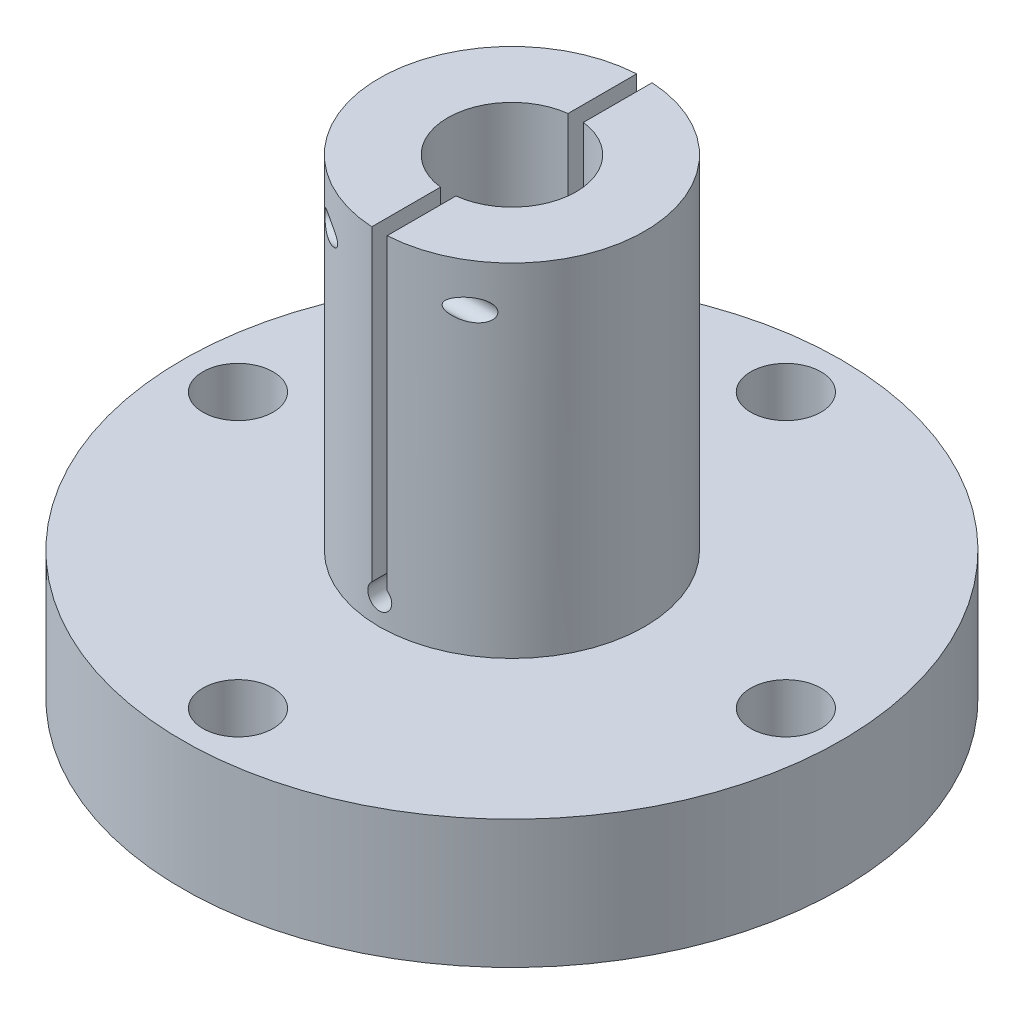
from build123d import *

# Parameters (mm, degrees)
CUT_EXTRUDE1_DEPTH      = 78.391860037
CUT_EXTRUDE1_DEPTH_BACK = 78.391860037
CUT_EXTRUDE2_START      = -2.5
SKETCH3_R               = 1.25
CUT_EXTRUDE2_DEPTH      = 76.343496909
SKETCH4_R               = 0.5
CUT_EXTRUDE3_DEPTH      = 80.13823356
SKETCH5_R               = 2.25
CUT_EXTRUDE4_DEPTH      = 78.391860108
SKETCH6_R               = 4.1
CUT_EXTRUDE5_DEPTH      = 9
CIRPATTERN1_COUNT       = 4


with BuildPart() as part:
    # Sketch1 → Revolve1 (revolve)
    with BuildSketch(Plane.XY):
        Polygon((7.5, 55), (7.5, 15), (9, 15), (9, 7), (25, 7), (25, 0), (38.5, 0), (38.5, 15), (15.5, 15), (15.5, 55), align=None)
    revolve(axis=Axis((0, 0, 0), (0, 1, 0)))

    # Sketch2 → Cut-Extrude1 (cut, two sides: drawn at the far end of the back side and taken through both)
    with BuildSketch(Plane.XY.offset(-CUT_EXTRUDE1_DEPTH_BACK)):
        with BuildLine():
            Line((-0.9, 55), (0.9, 55))
            Line((0.9, 55), (0.9, 19.072380529))
            ThreePointArc((0.9, 19.072380529), (0, 16.6), (-0.9, 19.072380529))
            Line((-0.9, 19.072380529), (-0.9, 55))
        make_face()
    extrude(amount=CUT_EXTRUDE1_DEPTH + CUT_EXTRUDE1_DEPTH_BACK, mode=Mode.SUBTRACT)

    # Sketch3 → Cut-Extrude2 (cut, through all)
    with BuildSketch(Plane(origin=(-0.9, 0, 0), x_dir=(0, 0, -1), z_dir=(1, 0, 0)).offset(CUT_EXTRUDE2_START)):
        with Locations((-13, 50)):
            Circle(SKETCH3_R)
        with Locations((13, 50)):
            Circle(SKETCH3_R)
    cut_extrude2 = extrude(amount=-CUT_EXTRUDE2_DEPTH, mode=Mode.SUBTRACT)

    # Sketch4 → Cut-Extrude3 (cut, through all)
    with BuildSketch(Plane.ZY.offset(3.4)):
        with Locations((13, 50)):
            Circle(SKETCH4_R)
        with Locations((-13, 50)):
            Circle(SKETCH4_R)
    extrude(amount=-CUT_EXTRUDE3_DEPTH, mode=Mode.SUBTRACT)

    # Mirror1: Cut-Extrude2 across plane
    add(cut_extrude2.mirror(Plane(origin=(0, 0, 0), x_dir=(0, 0, 1), z_dir=(1, 0, 0))), mode=Mode.SUBTRACT)

    # Sketch5 → Cut-Extrude4 (cut, through all)
    with BuildSketch(Plane.XZ):
        with Locations((32, 0)):
            Circle(SKETCH5_R)
    cut_extrude4 = extrude(amount=-CUT_EXTRUDE4_DEPTH, mode=Mode.SUBTRACT)

    # Sketch6 → Cut-Extrude5 (cut)
    with BuildSketch(Plane(origin=(0, 15, 0), x_dir=(1, 0, 0), z_dir=(0, 1, 0))):
        with Locations((32, 0)):
            Circle(SKETCH6_R)
    cut_extrude5 = extrude(amount=-CUT_EXTRUDE5_DEPTH, mode=Mode.SUBTRACT)

    # CirPattern1: Cut-Extrude4, Cut-Extrude5 ×4 about axis
    cirpattern1_axis = Axis((0, 55, 0), (0, -1, 0))
    add([cut_extrude4.rotate(cirpattern1_axis, i * 360 / CIRPATTERN1_COUNT) for i in range(1, CIRPATTERN1_COUNT)], mode=Mode.SUBTRACT)
    add([cut_extrude5.rotate(cirpattern1_axis, i * 360 / CIRPATTERN1_COUNT) for i in range(1, CIRPATTERN1_COUNT)], mode=Mode.SUBTRACT)


solid = part.part
